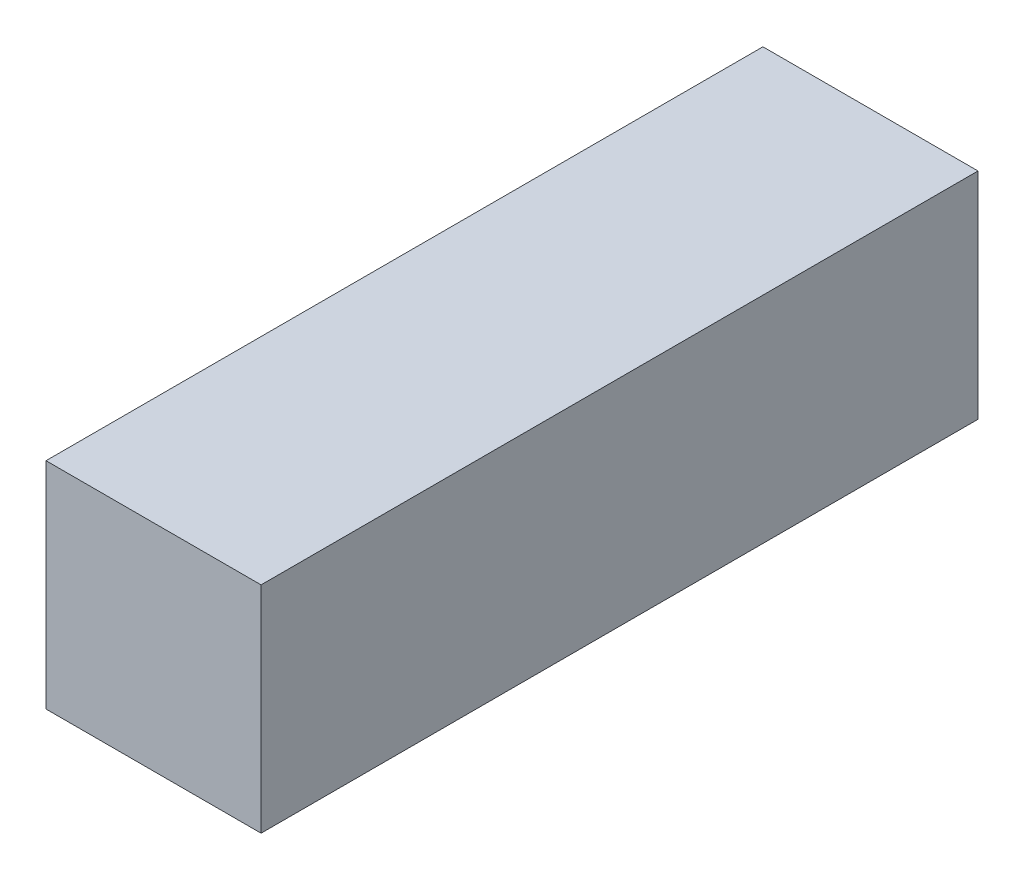
from build123d import *

# Parameters (mm, degrees)
SKETCH1_W           = 3.81
SKETCH1_H           = 3.81
BOSS_EXTRUDE1_DEPTH = 12.7


with BuildPart() as part:
    # Sketch1 → Boss-Extrude1 (new body)
    with BuildSketch(Plane.XY):
        Rectangle(SKETCH1_W, SKETCH1_H)
    extrude(amount=BOSS_EXTRUDE1_DEPTH)


solid = part.part
